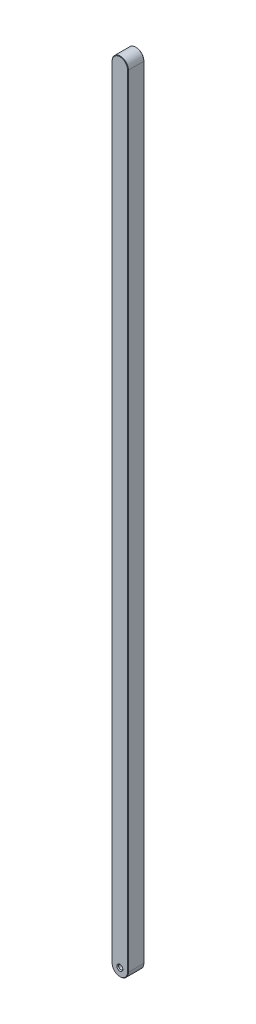
from build123d import *

# Parameters (mm, degrees)
BOSS_EXTRUDE1_DEPTH = 4.7625
CHAMFER1_SIZE       = 0.254


with BuildPart() as part:
    # Sketch1 → Boss-Extrude1 (new, symmetric)
    with BuildSketch(Plane.XY):
        with BuildLine():
            Line((-4.7625, 0), (-4.7625, 457.2))
            ThreePointArc((-4.7625, 457.2), (0, 461.9625), (4.7625, 457.2))
            Line((4.7625, 457.2), (4.7625, 0))
            ThreePointArc((4.7625, 0), (0, -4.7625), (-4.7625, 0))
        make_face()
    extrude(amount=BOSS_EXTRUDE1_DEPTH, both=True)

    # Sketch3 → M3x0.5 Tapped Hole1 (revolve, cut)
    with BuildSketch(Plane(origin=(0, 0, 4.7625), x_dir=(0, -1, 0), z_dir=(1, 0, 0))):
        Polygon((0, 0), (0, 9.525), (1.75, 9.525), (1.25, 9.025), (1.25, 0.5), (1.75, 0), align=None)
    revolve(axis=Axis((0, 0, 11.1125), (0, 0, -1)), mode=Mode.SUBTRACT)

    # Chamfer1
    chamfer1_edges = [part.edges().sort_by_distance(p)[0] for p in [
        (4.7625, 228.6, -4.7625),
        (0, 461.9625, -4.7625),
        (-4.7625, 228.6, -4.7625),
        (0, -4.7625, -4.7625),
        (-4.7625, 228.6, 4.7625),
        (0, 461.9625, 4.7625),
        (4.7625, 228.6, 4.7625),
        (0, -4.7625, 4.7625),
    ]]
    chamfer(chamfer1_edges, length=CHAMFER1_SIZE)


solid = part.part
